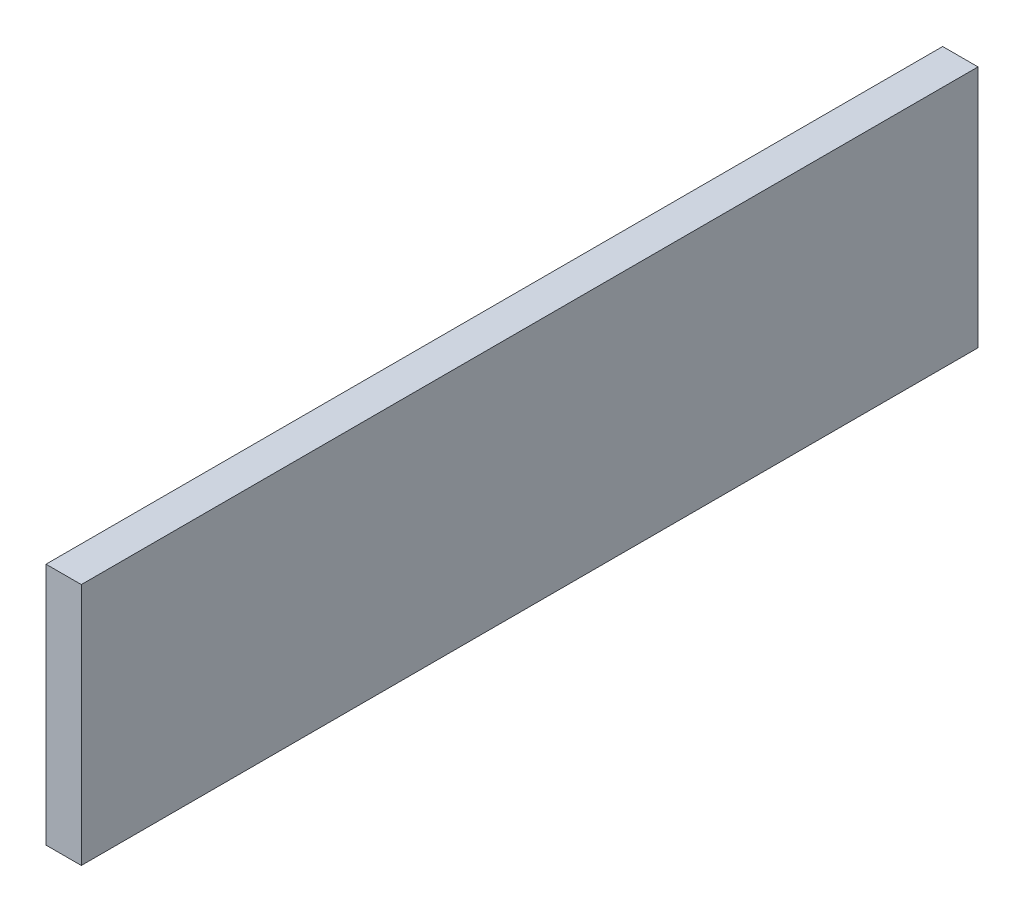
from build123d import *

# Parameters (mm, degrees)
SKETCH_1_W      = 457
SKETCH_1_H      = 124
EXTRUDE_1_DEPTH = 18


with BuildPart() as part:
    # Эскиз1 → Бобышка-Вытянуть1 (new body)
    with BuildSketch(Plane(origin=(0, 0, 0), x_dir=(0, 0, -1), z_dir=(1, 0, 0))):
        with Locations((182.895687411, 41.731416627)):
            Rectangle(SKETCH_1_W, SKETCH_1_H)
    extrude(amount=EXTRUDE_1_DEPTH)


solid = part.part
